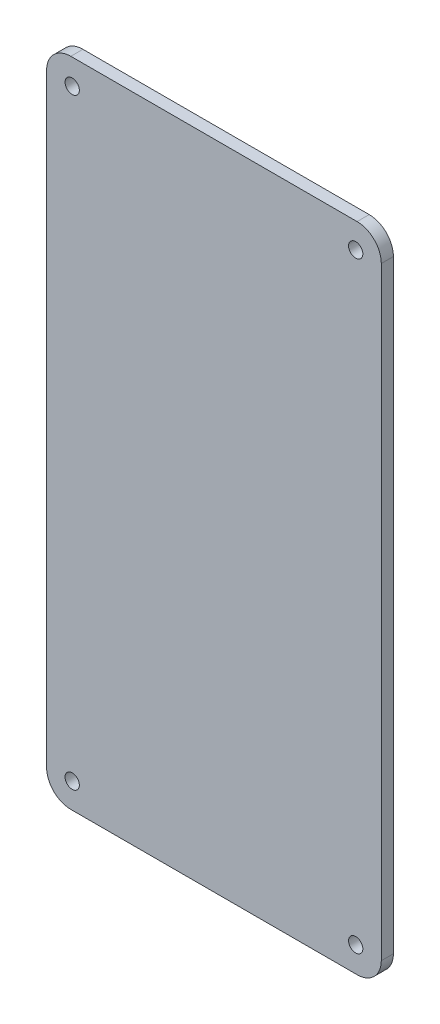
from build123d import *

# Parameters (mm, degrees)
BOSS_EXTRUDE1_DEPTH = 2.54
SKETCH2_R           = 1.5
CUT_EXTRUDE1_DEPTH  = 3.54


with BuildPart() as part:
    # Sketch1 → Boss-Extrude1 (new body)
    with BuildSketch(Plane.XY):
        with BuildLine():
            Line((-30.04505, -68.44755), (30.04505, -68.44755))
            ThreePointArc((30.04505, -68.44755), (33.637152448, -66.959652448), (35.12505, -63.36755))
            Line((35.12505, -63.36755), (35.12505, 63.36755))
            ThreePointArc((35.12505, 63.36755), (33.637152448, 66.959652448), (30.04505, 68.44755))
            Line((30.04505, 68.44755), (-30.04505, 68.44755))
            ThreePointArc((-30.04505, 68.44755), (-33.637152448, 66.959652448), (-35.12505, 63.36755))
            Line((-35.12505, 63.36755), (-35.12505, -63.36755))
            ThreePointArc((-35.12505, -63.36755), (-33.637152448, -66.959652448), (-30.04505, -68.44755))
        make_face()
    extrude(amount=BOSS_EXTRUDE1_DEPTH)

    # Sketch2 → Cut-Extrude1 (cut, through all)
    with BuildSketch(Plane.XY.offset(2.54)):
        with Locations((-29.75, 63.1515)):
            Circle(SKETCH2_R)
        with Locations((29.75, 63.1515)):
            Circle(SKETCH2_R)
        with Locations((29.75, -63.1515)):
            Circle(SKETCH2_R)
        with Locations((-29.75, -63.1515)):
            Circle(SKETCH2_R)
    extrude(amount=-CUT_EXTRUDE1_DEPTH, mode=Mode.SUBTRACT)


solid = part.part
